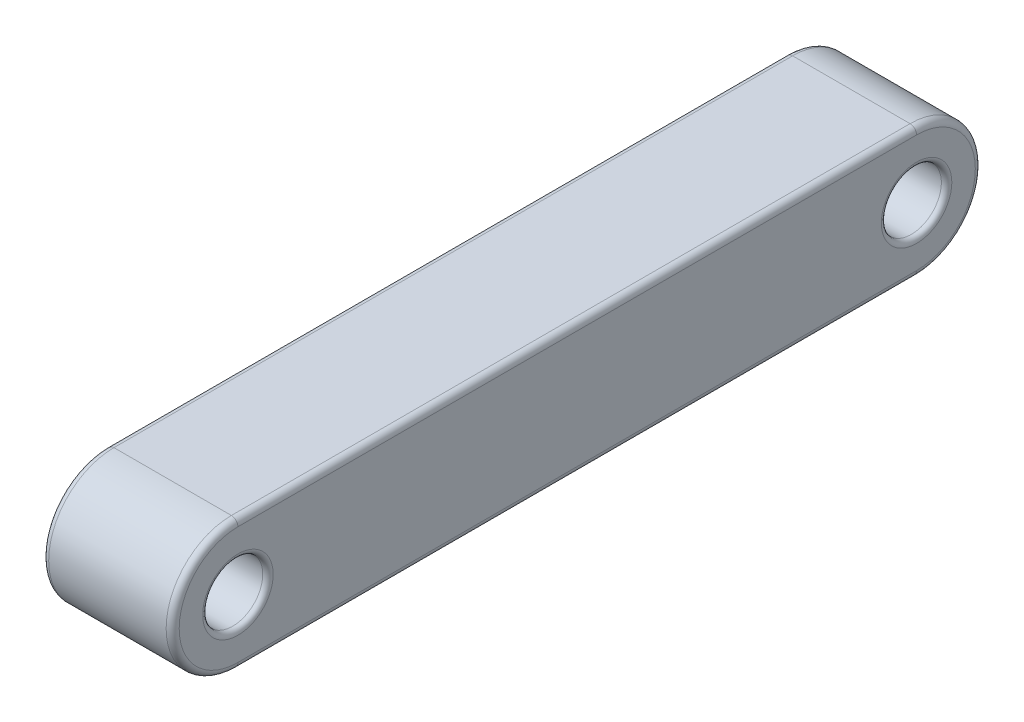
from build123d import *

# Parameters (mm, degrees)
SKETCH1_R           = 0.575
BOSS_EXTRUDE1_DEPTH = 2.5
FILLET1_R           = 0.125
FILLET2_R           = 0.1


with BuildPart() as part:
    # Sketch1 → Boss-Extrude1 (new body)
    with BuildSketch(Plane(origin=(0, 0, 0), x_dir=(0, 0, -1), z_dir=(1, 0, 0))):
        with BuildLine():
            ThreePointArc((12, 0), (13.25, -1.25), (12, -2.5))
            Line((12, -2.5), (11, -2.5))
            Line((11, -2.5), (0, -2.5))
            Line((0, -2.5), (-1, -2.5))
            ThreePointArc((-1, -2.5), (-2.25, -1.25), (-1, 0))
            Line((-1, 0), (0, 0))
            Line((0, 0), (11, 0))
            Line((11, 0), (12, 0))
        make_face()
        with Locations((12, -1.25)):
            Circle(SKETCH1_R, mode=Mode.SUBTRACT)
        with Locations((-1, -1.25)):
            Circle(SKETCH1_R, mode=Mode.SUBTRACT)
    extrude(amount=BOSS_EXTRUDE1_DEPTH)

    # Fillet1
    fillet1_edges = [part.edges().sort_by_distance(p)[0] for p in [
        (0, -1.25, 2.25),
        (0, 0, -5.5),
        (0, -1.25, -13.25),
        (2.5, 0, -5.5),
        (2.5, -1.25, 2.25),
        (2.5, -2.5, -5.5),
        (2.5, -1.25, -13.25),
        (0, -2.5, -5.5),
    ]]
    fillet(fillet1_edges, radius=FILLET1_R)

    # Fillet2
    fillet2_edges = [part.edges().sort_by_distance(p)[0] for p in [
        (2.5, -1.25, -11.425),
        (2.5, -1.25, 1.575),
        (0, -1.25, 1.575),
        (0, -1.25, -11.425),
    ]]
    fillet(fillet2_edges, radius=FILLET2_R)


solid = part.part
